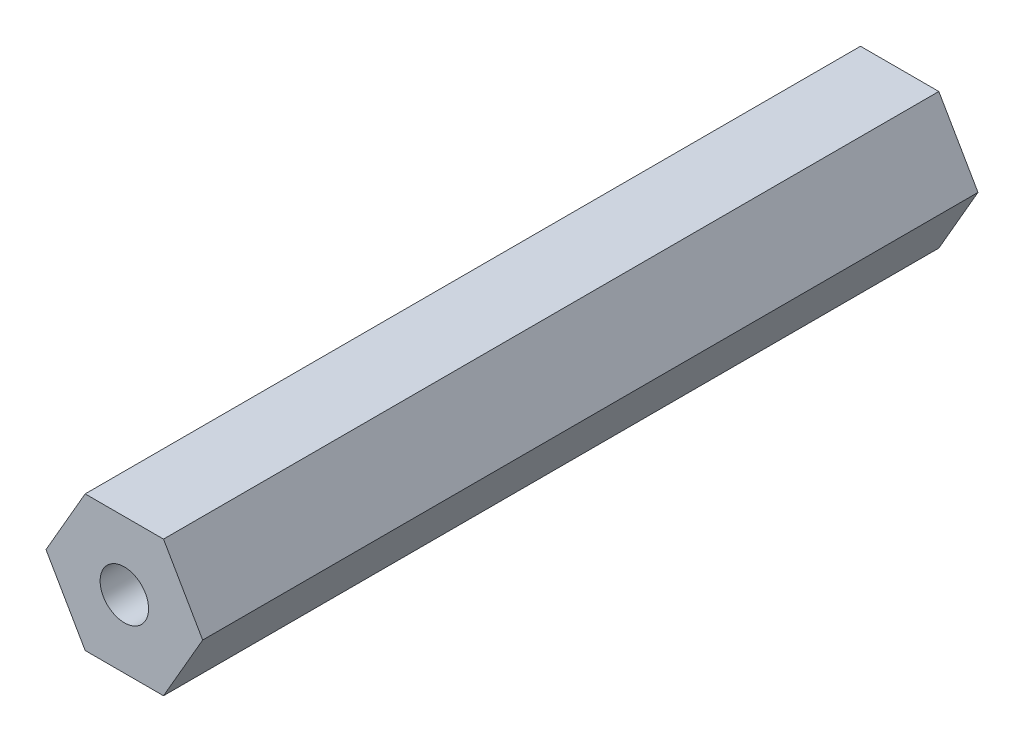
from build123d import *

# Parameters (mm, degrees)
EXTRUDE_1_DEPTH = 40
M3X0_5_1_D      = 2.5


with BuildPart() as part:
    # 草圖1 → 填料-伸長1 (new body)
    with BuildSketch(Plane.XY):
        Polygon((-2.020725942, 3.5), (-4.041451884, 0), (-2.020725942, -3.5), (2.020725942, -3.5), (4.041451884, 0), (2.020725942, 3.5), align=None)
    extrude(amount=EXTRUDE_1_DEPTH)

    # M3x0.5 螺紋孔1 (through all)
    with Locations(Plane.XY.offset(40)):
        with Locations((0, 0)):
            Hole(M3X0_5_1_D / 2)


solid = part.part
